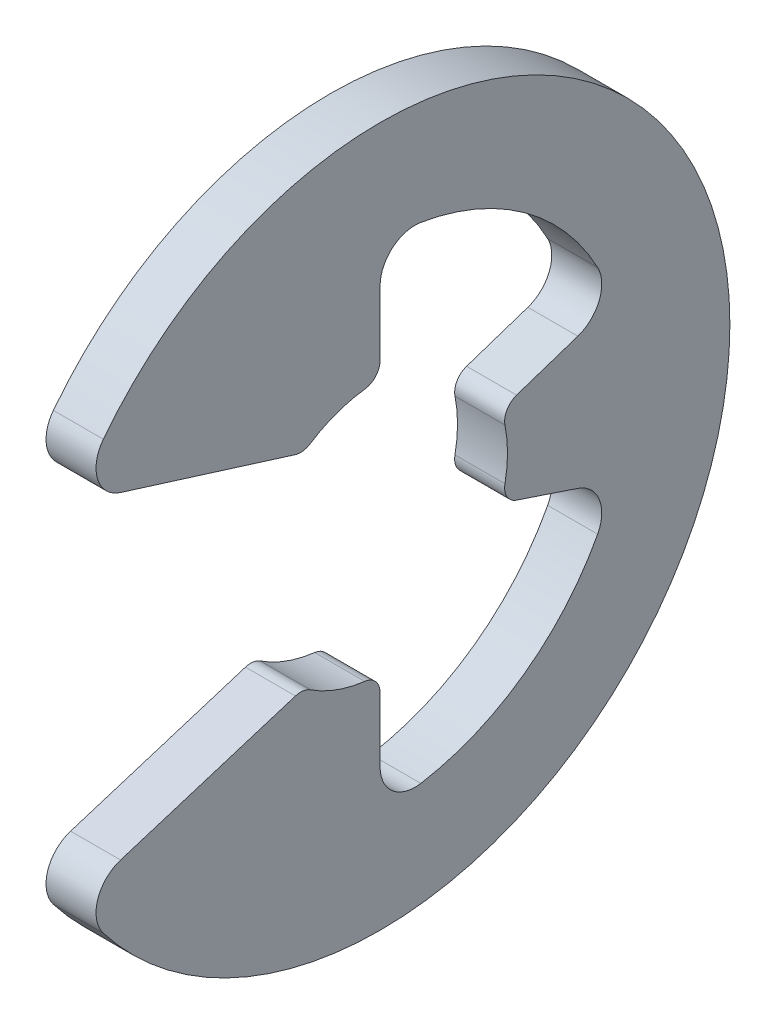
from build123d import *

# Parameters (mm, degrees)
BOSS_EXTRUDE1_DEPTH      = 0.127
BOSS_EXTRUDE1_DEPTH_BACK = 0.127
FILLET1_R                = 0.1778
FILLET2_R                = 0.0889


with BuildPart() as part:
    # Sketch3 → Boss-Extrude1 (new body, two sides)
    with BuildSketch(Plane(origin=(0, 0, 0), x_dir=(0, 0, -1), z_dir=(1, 0, 0))) as boss_extrude1_sk:
        with BuildLine():
            Line((0.614462172, -0.204820724), (1.187727007, -0.395909002))
            ThreePointArc((1.187727007, -0.395909002), (0.732042187, -1.015654281), (0, -1.251974194))
            Line((0, -1.251974194), (0, -0.6477))
            ThreePointArc((0, -0.6477), (-0.204820724, -0.614462172), (-0.38862, -0.51816))
            Line((-0.38862, -0.51816), (-1.545258105, -0.879466537))
            ThreePointArc((-1.545258105, -0.879466537), (1.778, 0), (-1.545258105, 0.879466537))
            Line((-1.545258105, 0.879466537), (-0.38862, 0.51816))
            ThreePointArc((-0.38862, 0.51816), (-0.204820724, 0.614462172), (0, 0.6477))
            Line((0, 0.6477), (0, 1.251974194))
            ThreePointArc((0, 1.251974194), (0.732042187, 1.015654281), (1.187727007, 0.395909002))
            Line((1.187727007, 0.395909002), (0.614462172, 0.204820724))
            ThreePointArc((0.614462172, 0.204820724), (0.6477, 0), (0.614462172, -0.204820724))
        make_face()
    extrude(amount=BOSS_EXTRUDE1_DEPTH)
    extrude(boss_extrude1_sk.sketch, amount=-BOSS_EXTRUDE1_DEPTH_BACK)

    # Fillet1
    fillet1_edges = [part.edges().sort_by_distance(p)[0] for p in [
        (0, 0.395909002, -1.187727007),
        (0, 1.251974194, 0),
        (0, 0.879466537, 1.545258105),
        (0, -0.879466537, 1.545258105),
        (0, -1.251974194, 0),
        (0, -0.395909002, -1.187727007),
    ]]
    fillet(fillet1_edges, radius=FILLET1_R)

    # Fillet2
    fillet2_edges = [part.edges().sort_by_distance(p)[0] for p in [
        (0, 0.204820724, -0.614462172),
        (0, 0.6477, 0),
        (0, 0.51816, 0.38862),
        (0, -0.51816, 0.38862),
        (0, -0.6477, 0),
        (0, -0.204820724, -0.614462172),
    ]]
    fillet(fillet2_edges, radius=FILLET2_R)


solid = part.part
